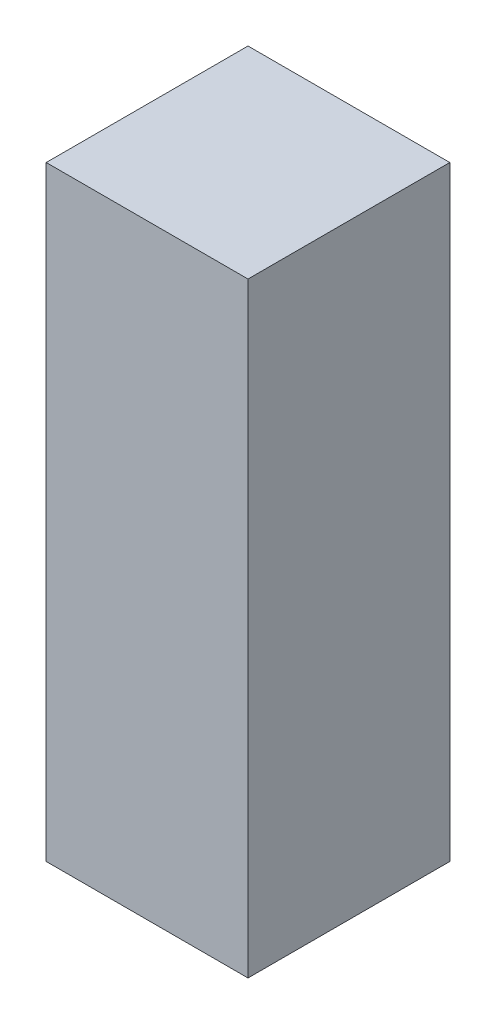
from build123d import *

# Parameters (mm, degrees)
SKETCH1_W           = 10000
SKETCH1_H           = 10000
BOSS_EXTRUDE1_DEPTH = 30000


with BuildPart() as part:
    # Sketch1 → Boss-Extrude1 (new body)
    with BuildSketch(Plane(origin=(0, 0, 0), x_dir=(1, 0, 0), z_dir=(0, 1, 0))):
        Rectangle(SKETCH1_W, SKETCH1_H)
    extrude(amount=BOSS_EXTRUDE1_DEPTH)


solid = part.part
